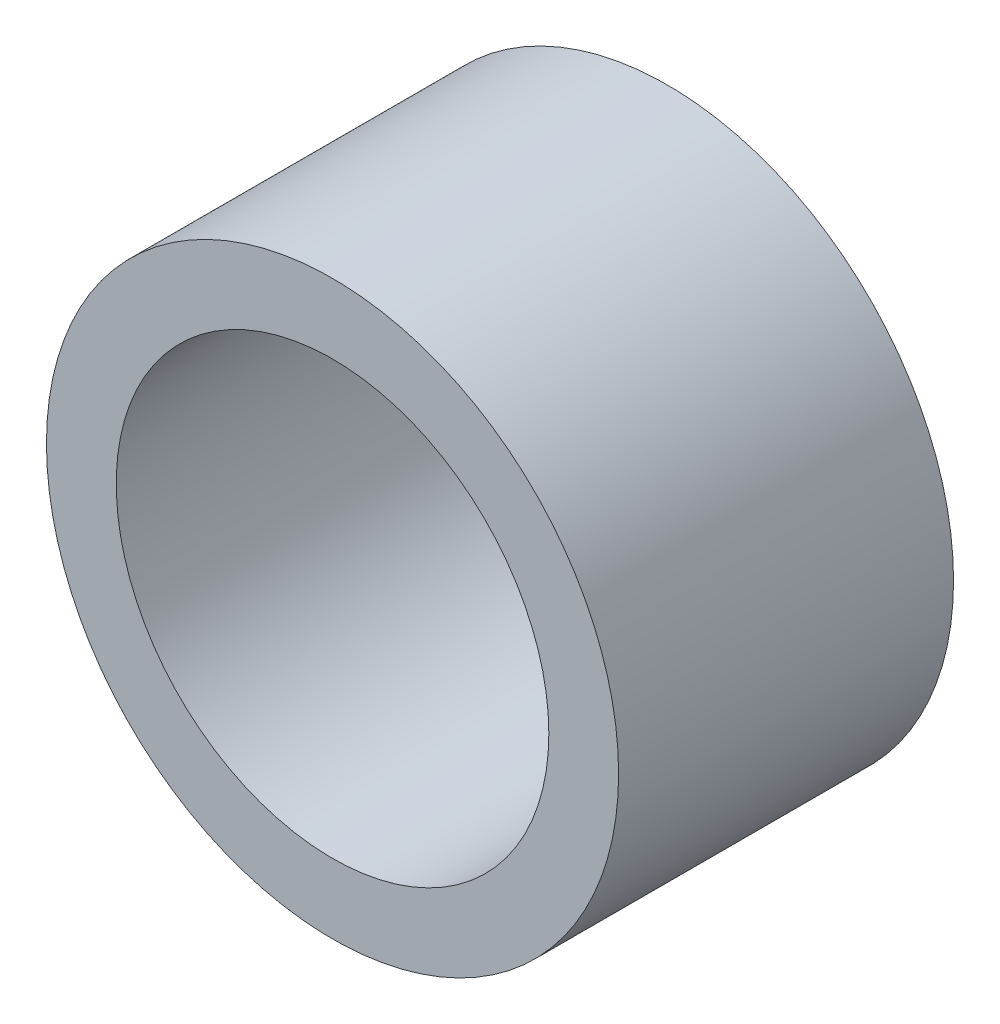
from build123d import *

# Parameters (mm, degrees)
SKETCH1_R           = 5.207
SKETCH1_R_2         = 3.937
BOSS_EXTRUDE1_DEPTH = 6.096


with BuildPart() as part:
    # Sketch1 → Boss-Extrude1 (new body)
    with BuildSketch(Plane.XY):
        Circle(SKETCH1_R)
        Circle(SKETCH1_R_2, mode=Mode.SUBTRACT)
    extrude(amount=BOSS_EXTRUDE1_DEPTH)


solid = part.part
